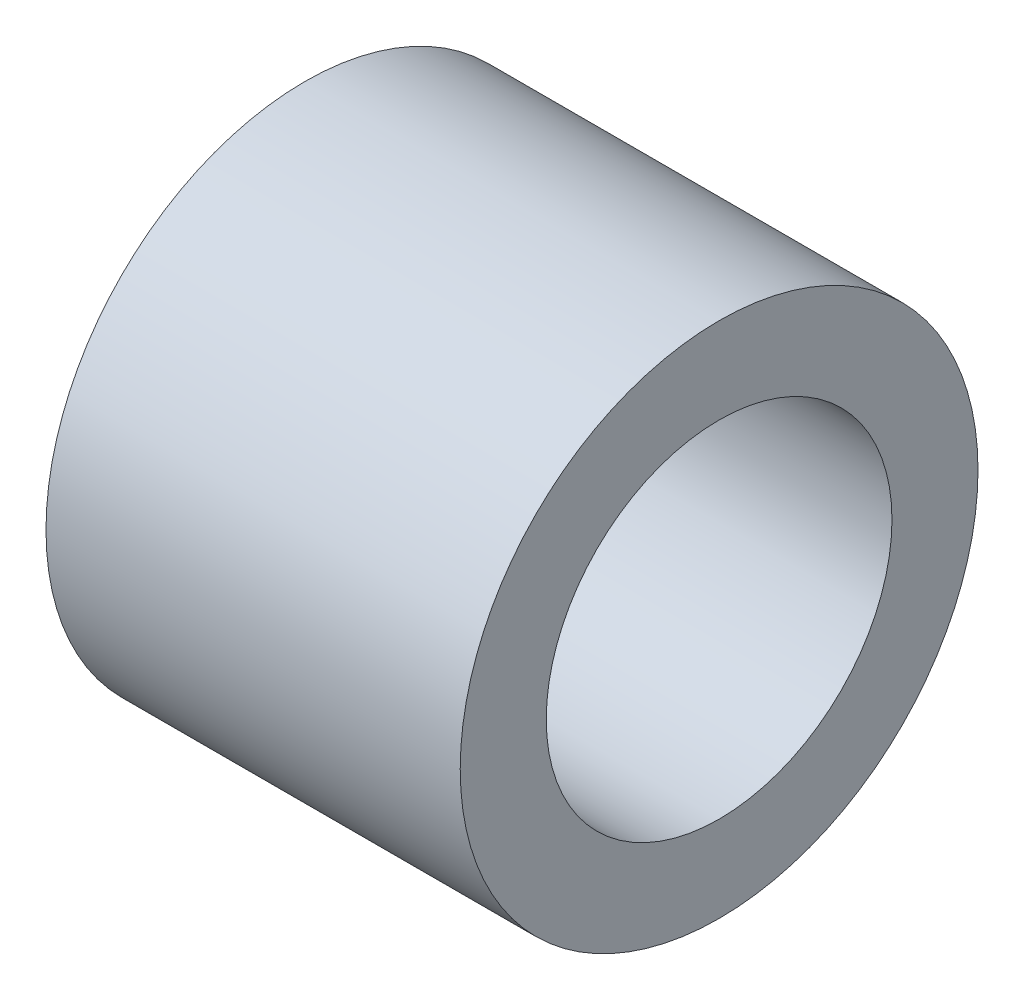
from build123d import *

# Parameters (mm, degrees)
SKETCH1_R           = 3.96875
SKETCH1_R_2         = 2.65
BOSS_EXTRUDE1_DEPTH = 6.35


with BuildPart() as part:
    # Sketch1 → Boss-Extrude1 (new body)
    with BuildSketch(Plane(origin=(0, 0, 0), x_dir=(0, 0, -1), z_dir=(1, 0, 0))):
        Circle(SKETCH1_R)
        Circle(SKETCH1_R_2, mode=Mode.SUBTRACT)
    extrude(amount=BOSS_EXTRUDE1_DEPTH)


solid = part.part
